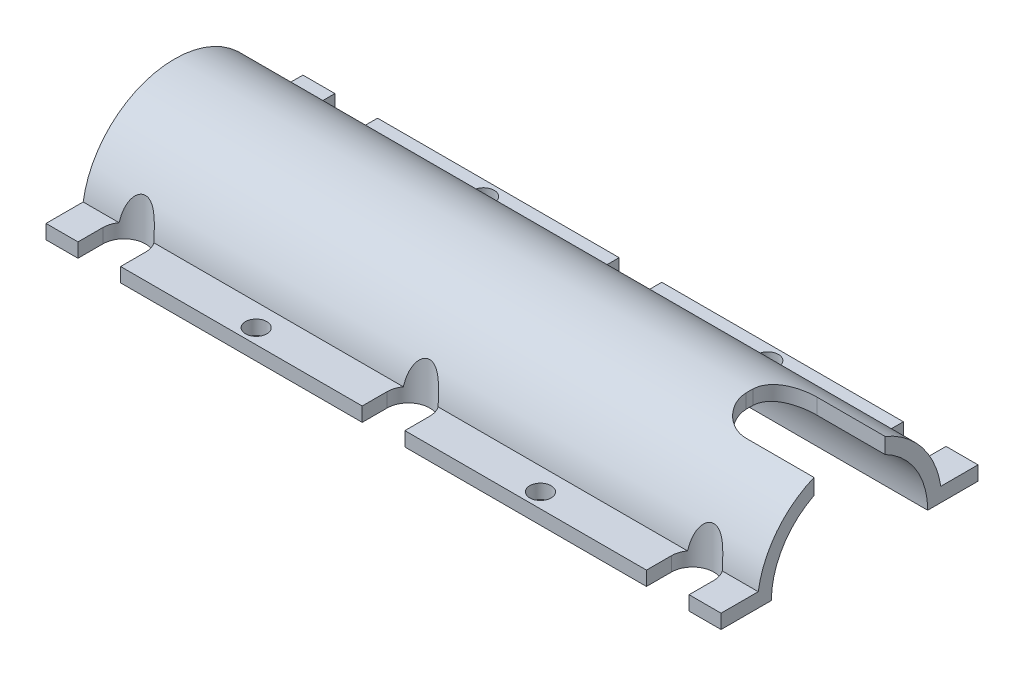
from build123d import *

# Parameters (mm, degrees)
EXTRUDE_1_DEPTH          = 95
SKETCH_2_R               = 1.5
CUT_EXTRUDE_1_DEPTH      = 12.002837415
CUT_EXTRUDE_1_DEPTH_BACK = 3.00301723
CUT_EXTRUDE_2_DEPTH      = 14.002837554


with BuildPart() as part:
    # Эскиз1 → Бобышка-Вытянуть1 (new body)
    with BuildSketch(Plane(origin=(0, 0, 0), x_dir=(0, 0, -1), z_dir=(1, 0, 0))):
        with BuildLine():
            Line((11, 0), (18.079487192, 0))
            Line((18.079487192, 0), (18.079487192, 2))
            Line((18.079487192, 2), (12.848104212, 2))
            ThreePointArc((12.848104212, 2), (0.000220895, 13.002837452), (-12.848036252, 2.000436531))
            Line((-12.848036252, 2.000436531), (-18.079487192, 2))
            Line((-18.079487192, 2), (-18.079487192, 0))
            Line((-18.079487192, 0), (-11, 0))
            ThreePointArc((-11, 0), (0, 11), (11, 0))
        make_face()
    extrude(amount=EXTRUDE_1_DEPTH)

    # Эскиз2 → Вырез-Вытянуть1 (cut, two sides)
    with BuildSketch(Plane(origin=(0, 2.001508604, 0.000167013), x_dir=(1, 0, 0), z_dir=(0, 0.999999997, 8.3444e-05))) as cut_extrude_1_sk:
        with Locations((27.5, -16)):
            Circle(SKETCH_2_R)
        with Locations((67.5, -16)):
            Circle(SKETCH_2_R)
        with Locations((67.5, 16)):
            Circle(SKETCH_2_R)
        with Locations((27.5, 16)):
            Circle(SKETCH_2_R)
        with BuildLine():
            Line((4.5, -14.579320241), (4.5, -18.29882224))
            Line((4.5, -18.29882224), (10.5, -18.29882224))
            Line((10.5, -18.29882224), (10.5, -14.579320241))
            ThreePointArc((10.5, -14.579320241), (7.5, -11.579320241), (4.5, -14.579320241))
        make_face()
        with BuildLine():
            Line((50.5, -18.29882224), (50.5, -14.579320241))
            ThreePointArc((50.5, -14.579320241), (47.5, -11.579320241), (44.5, -14.579320241))
            Line((44.5, -14.579320241), (44.5, -18.29882224))
            Line((44.5, -18.29882224), (50.5, -18.29882224))
        make_face()
        with BuildLine():
            Line((90.5, -18.29882224), (90.5, -14.579320241))
            ThreePointArc((90.5, -14.579320241), (87.5, -11.579320241), (84.5, -14.579320241))
            Line((84.5, -14.579320241), (84.5, -18.29882224))
            Line((84.5, -18.29882224), (90.5, -18.29882224))
        make_face()
        with BuildLine():
            Line((84.5, 18.29882224), (90.5, 18.29882224))
            Line((90.5, 18.29882224), (90.5, 14.579320241))
            ThreePointArc((90.5, 14.579320241), (87.5, 11.579320241), (84.5, 14.579320241))
            Line((84.5, 14.579320241), (84.5, 18.29882224))
        make_face()
        with BuildLine():
            Line((44.5, 18.29882224), (50.5, 18.29882224))
            Line((50.5, 18.29882224), (50.5, 14.579320241))
            ThreePointArc((50.5, 14.579320241), (47.5, 11.579320241), (44.5, 14.579320241))
            Line((44.5, 14.579320241), (44.5, 18.29882224))
        make_face()
        with BuildLine():
            Line((4.5, 18.29882224), (10.5, 18.29882224))
            Line((10.5, 18.29882224), (10.5, 14.579320241))
            ThreePointArc((10.5, 14.579320241), (7.5, 11.579320241), (4.5, 14.579320241))
            Line((4.5, 14.579320241), (4.5, 18.29882224))
        make_face()
    extrude(amount=CUT_EXTRUDE_1_DEPTH, mode=Mode.SUBTRACT)
    extrude(cut_extrude_1_sk.sketch, amount=-CUT_EXTRUDE_1_DEPTH_BACK, mode=Mode.SUBTRACT)

    # Эскиз3 → Вырез-Вытянуть2 (cut, through all)
    with BuildSketch(Plane.XZ):
        with BuildLine():
            Line((85.409616901, 5), (95, 5))
            Line((95, 5), (95, -5))
            Line((95, -5), (85.409616901, -5))
            ThreePointArc((85.409616901, -5), (82.227636386, -3.681980515), (80.909616901, -0.5))
            Line((80.909616901, -0.5), (80.909616901, 0.5))
            ThreePointArc((80.909616901, 0.5), (82.227636386, 3.681980515), (85.409616901, 5))
        make_face()
    extrude(amount=-CUT_EXTRUDE_2_DEPTH, mode=Mode.SUBTRACT)


solid = part.part
